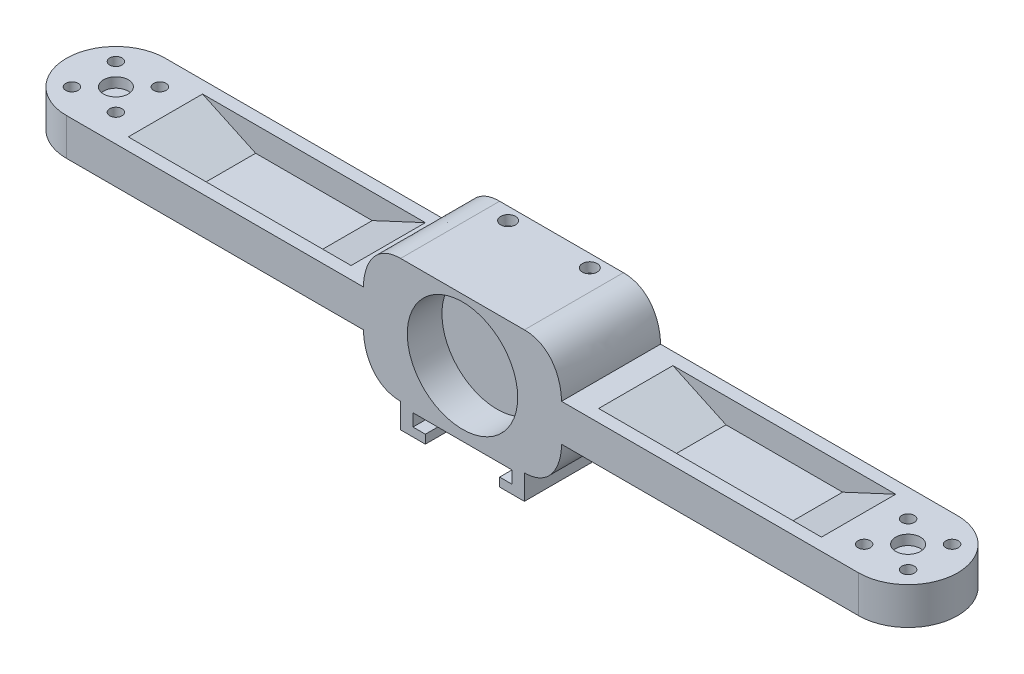
from build123d import *

# Parameters (mm, degrees)
BOSS_EXTRUDE1_DEPTH = 25
SKETCH2_R           = 11.15
CUT_EXTRUDE1_DEPTH  = 7
CUT_EXTRUDE2_DEPTH  = 8.75
CUT_EXTRUDE3_DEPTH  = 8.75
SKETCH5_W           = 25
SKETCH5_H           = 20.5
CUT_EXTRUDE4_DEPTH  = 8
SKETCH9_R           = 2.5
CUT_EXTRUDE5_DEPTH  = 2
CUT_EXTRUDE6_REACH  = 18.25
SKETCH10_R          = 1.25
SKETCH13_R          = 2.4
CUT_EXTRUDE7_DEPTH  = 4.5
SKETCH14_R          = 1.5
CUT_EXTRUDE8_DEPTH  = 2
CUT_EXTRUDE10_DEPTH = 20
BOSS_EXTRUDE2_DEPTH = 20
SKETCH18_W          = 45
SKETCH18_H          = 15
CUT_EXTRUDE11_DEPTH = 5
BOSS_EXTRUDE3_DEPTH = 20


with BuildPart() as part:
    # Sketch1 → Boss-Extrude1 (new body)
    with BuildSketch(Plane(origin=(0, 0, 0), x_dir=(1, 0, 0), z_dir=(0, 1, 0))):
        with BuildLine():
            Line((-80, 10), (80, 10))
            ThreePointArc((80, 10), (90, 0), (80, -10))
            Line((80, -10), (-80, -10))
            ThreePointArc((-80, -10), (-90, 0), (-80, 10))
        make_face()
    extrude(amount=BOSS_EXTRUDE1_DEPTH)

    # Sketch2 → Cut-Extrude1 (cut)
    with BuildSketch(Plane.XY.offset(10)):
        with Locations((0, 12.5)):
            Circle(SKETCH2_R)
    extrude(amount=-CUT_EXTRUDE1_DEPTH, mode=Mode.SUBTRACT)

    # Sketch3 → Cut-Extrude2 (cut)
    with BuildSketch(Plane(origin=(0, 25, 0), x_dir=(1, 0, 0), z_dir=(0, 1, 0))):
        with BuildLine():
            Line((-20, 10), (-20, -10))
            Line((-20, -10), (-80, -10))
            ThreePointArc((-80, -10), (-90, 0), (-80, 10))
            Line((-80, 10), (-20, 10))
        make_face()
        with BuildLine():
            Line((20, 10), (20, -10))
            Line((20, -10), (80, -10))
            ThreePointArc((80, -10), (90, 0), (80, 10))
            Line((80, 10), (20, 10))
        make_face()
    extrude(amount=-CUT_EXTRUDE2_DEPTH, mode=Mode.SUBTRACT)

    # Sketch4 → Cut-Extrude3 (cut)
    with BuildSketch(Plane.XZ):
        with BuildLine():
            Line((20, 10), (20, -10))
            Line((20, -10), (80, -10))
            ThreePointArc((80, -10), (90, 0), (80, 10))
            Line((80, 10), (20, 10))
        make_face()
        with BuildLine():
            Line((-20, 10), (-20, -10))
            Line((-20, -10), (-80, -10))
            ThreePointArc((-80, -10), (-90, 0), (-80, 10))
            Line((-80, 10), (-20, 10))
        make_face()
    extrude(amount=-CUT_EXTRUDE3_DEPTH, mode=Mode.SUBTRACT)

    # Sketch5 → Cut-Extrude4 (cut)
    with BuildSketch(Plane(origin=(0, 0, -10), x_dir=(-1, 0, 0), z_dir=(0, 0, -1))):
        with Locations((0, 12.5)):
            Rectangle(SKETCH5_W, SKETCH5_H)
    extrude(amount=-CUT_EXTRUDE4_DEPTH, mode=Mode.SUBTRACT)

    # Sketch9 → Cut-Extrude5 (cut)
    with BuildSketch(Plane(origin=(0, 16.25, 0), x_dir=(1, 0, 0), z_dir=(0, 1, 0))):
        with Locations((-80, 0)):
            Circle(SKETCH9_R)
        with Locations((80, 0)):
            Circle(SKETCH9_R)
    extrude(amount=-CUT_EXTRUDE5_DEPTH, mode=Mode.SUBTRACT)

    # Sketch10 → Cut-Extrude6 (cut, up to next)
    with BuildSketch(Plane(origin=(0, 16.25, 0), x_dir=(1, 0, 0), z_dir=(0, 1, 0)), mode=Mode.PRIVATE) as cut_extrude6_sk1:
        with Locations((-75.56, 4.44)):
            Circle(SKETCH10_R)
    cut_extrude6_tool1 = extrude(cut_extrude6_sk1.sketch, amount=-CUT_EXTRUDE6_REACH, mode=Mode.PRIVATE) & part.part
    add(cut_extrude6_tool1.solids().sort_by_distance((-75.56, 16.25, -4.44))[0], mode=Mode.SUBTRACT)
    # Sketch10 → Cut-Extrude6 (cut, up to next)
    with BuildSketch(Plane(origin=(0, 16.25, 0), x_dir=(1, 0, 0), z_dir=(0, 1, 0)), mode=Mode.PRIVATE) as cut_extrude6_sk2:
        with Locations((-75.56, -4.44)):
            Circle(SKETCH10_R)
    cut_extrude6_tool2 = extrude(cut_extrude6_sk2.sketch, amount=-CUT_EXTRUDE6_REACH, mode=Mode.PRIVATE) & part.part
    add(cut_extrude6_tool2.solids().sort_by_distance((-75.56, 16.25, 4.44))[0], mode=Mode.SUBTRACT)
    # Sketch10 → Cut-Extrude6 (cut, up to next)
    with BuildSketch(Plane(origin=(0, 16.25, 0), x_dir=(1, 0, 0), z_dir=(0, 1, 0)), mode=Mode.PRIVATE) as cut_extrude6_sk3:
        with Locations((-84.44, -4.44)):
            Circle(SKETCH10_R)
    cut_extrude6_tool3 = extrude(cut_extrude6_sk3.sketch, amount=-CUT_EXTRUDE6_REACH, mode=Mode.PRIVATE) & part.part
    add(cut_extrude6_tool3.solids().sort_by_distance((-84.44, 16.25, 4.44))[0], mode=Mode.SUBTRACT)
    # Sketch10 → Cut-Extrude6 (cut, up to next)
    with BuildSketch(Plane(origin=(0, 16.25, 0), x_dir=(1, 0, 0), z_dir=(0, 1, 0)), mode=Mode.PRIVATE) as cut_extrude6_sk4:
        with Locations((-84.44, 4.44)):
            Circle(SKETCH10_R)
    cut_extrude6_tool4 = extrude(cut_extrude6_sk4.sketch, amount=-CUT_EXTRUDE6_REACH, mode=Mode.PRIVATE) & part.part
    add(cut_extrude6_tool4.solids().sort_by_distance((-84.44, 16.25, -4.44))[0], mode=Mode.SUBTRACT)
    # Sketch10 → Cut-Extrude6 (cut, up to next)
    with BuildSketch(Plane(origin=(0, 16.25, 0), x_dir=(1, 0, 0), z_dir=(0, 1, 0)), mode=Mode.PRIVATE) as cut_extrude6_sk5:
        with Locations((84.44, 4.44)):
            Circle(SKETCH10_R)
    cut_extrude6_tool5 = extrude(cut_extrude6_sk5.sketch, amount=-CUT_EXTRUDE6_REACH, mode=Mode.PRIVATE) & part.part
    add(cut_extrude6_tool5.solids().sort_by_distance((84.44, 16.25, -4.44))[0], mode=Mode.SUBTRACT)
    # Sketch10 → Cut-Extrude6 (cut, up to next)
    with BuildSketch(Plane(origin=(0, 16.25, 0), x_dir=(1, 0, 0), z_dir=(0, 1, 0)), mode=Mode.PRIVATE) as cut_extrude6_sk6:
        with Locations((84.44, -4.44)):
            Circle(SKETCH10_R)
    cut_extrude6_tool6 = extrude(cut_extrude6_sk6.sketch, amount=-CUT_EXTRUDE6_REACH, mode=Mode.PRIVATE) & part.part
    add(cut_extrude6_tool6.solids().sort_by_distance((84.44, 16.25, 4.44))[0], mode=Mode.SUBTRACT)
    # Sketch10 → Cut-Extrude6 (cut, up to next)
    with BuildSketch(Plane(origin=(0, 16.25, 0), x_dir=(1, 0, 0), z_dir=(0, 1, 0)), mode=Mode.PRIVATE) as cut_extrude6_sk7:
        with Locations((75.56, -4.44)):
            Circle(SKETCH10_R)
    cut_extrude6_tool7 = extrude(cut_extrude6_sk7.sketch, amount=-CUT_EXTRUDE6_REACH, mode=Mode.PRIVATE) & part.part
    add(cut_extrude6_tool7.solids().sort_by_distance((75.56, 16.25, 4.44))[0], mode=Mode.SUBTRACT)
    # Sketch10 → Cut-Extrude6 (cut, up to next)
    with BuildSketch(Plane(origin=(0, 16.25, 0), x_dir=(1, 0, 0), z_dir=(0, 1, 0)), mode=Mode.PRIVATE) as cut_extrude6_sk8:
        with Locations((75.56, 4.44)):
            Circle(SKETCH10_R)
    cut_extrude6_tool8 = extrude(cut_extrude6_sk8.sketch, amount=-CUT_EXTRUDE6_REACH, mode=Mode.PRIVATE) & part.part
    add(cut_extrude6_tool8.solids().sort_by_distance((75.56, 16.25, -4.44))[0], mode=Mode.SUBTRACT)

    # Sketch13 → Cut-Extrude7 (cut)
    with BuildSketch(Plane.XZ.offset(-8.75)):
        with Locations((-75.56, 4.44)):
            Circle(SKETCH13_R)
        with Locations((-75.56, -4.44)):
            Circle(SKETCH13_R)
        with Locations((-84.44, -4.44)):
            Circle(SKETCH13_R)
        with Locations((-84.44, 4.44)):
            Circle(SKETCH13_R)
        with Locations((84.44, 4.44)):
            Circle(SKETCH13_R)
        with Locations((84.44, -4.44)):
            Circle(SKETCH13_R)
        with Locations((75.56, -4.44)):
            Circle(SKETCH13_R)
        with Locations((75.56, 4.44)):
            Circle(SKETCH13_R)
    extrude(amount=-CUT_EXTRUDE7_DEPTH, mode=Mode.SUBTRACT)

    # Sketch14 → Cut-Extrude8 (cut)
    with BuildSketch(Plane(origin=(0, 25, 0), x_dir=(1, 0, 0), z_dir=(0, 1, 0))):
        with Locations((-8.25, 7.46)):
            Circle(SKETCH14_R)
        with Locations((8.25, 7.46)):
            Circle(SKETCH14_R)
    extrude(amount=-CUT_EXTRUDE8_DEPTH, mode=Mode.SUBTRACT)

    # Sketch16 → Cut-Extrude10 (cut)
    with BuildSketch(Plane(origin=(0, 0, -10), x_dir=(-1, 0, 0), z_dir=(0, 0, -1))):
        with BuildLine():
            Line((-12.5, 25), (-20, 25))
            Line((-20, 25), (-20, 16.25))
            add(Edge.make_bspline(
                [(-20, 16.25), (-20, 20.091476857), (-17.882145689, 25), (-12.5, 25)],
                knots=[0, 0, 0, 0, 1, 1, 1, 1], degree=3))
        make_face()
        with BuildLine():
            Line((12.5, 25), (20, 25))
            Line((20, 25), (20, 16.25))
            add(Edge.make_bspline(
                [(20, 16.25), (20, 20.091476857), (17.882145689, 25), (12.5, 25)],
                knots=[0, 0, 0, 0, 1, 1, 1, 1], degree=3))
        make_face()
        with BuildLine():
            Line((20, 0), (20, 8.75))
            add(Edge.make_bspline(
                [(20, 8.75), (20, 4.908523143), (17.882145689, 0), (12.5, 0)],
                knots=[0, 0, 0, 0, 1, 1, 1, 1], degree=3))
            Line((12.5, 0), (20, 0))
        make_face()
        with BuildLine():
            Line((-20, 0), (-20, 8.75))
            add(Edge.make_bspline(
                [(-20, 8.75), (-20, 4.908523143), (-17.882145689, 0), (-12.5, 0)],
                knots=[0, 0, 0, 0, 1, 1, 1, 1], degree=3))
            Line((-12.5, 0), (-20, 0))
        make_face()
    extrude(amount=-CUT_EXTRUDE10_DEPTH, mode=Mode.SUBTRACT)

    # Sketch17 → Boss-Extrude2 (add)
    with BuildSketch(Plane(origin=(0, 0, -10), x_dir=(-1, 0, 0), z_dir=(0, 0, -1))):
        Polygon((12.5, 0), (12.5, -5), (7.5, -5), (7.5, -3.25), (10, -3.25), (10, -0.75), (-10, -0.75), (-10, -3.25), (-7.5, -3.25), (-7.5, -5), (-12.5, -5), (-12.5, 0), align=None)
    extrude(amount=-BOSS_EXTRUDE2_DEPTH)

    # Sketch18 → Cut-Extrude11 (cut)
    with BuildSketch(Plane(origin=(0, 16.25, 0), x_dir=(1, 0, 0), z_dir=(0, 1, 0))):
        with Locations((47.5, 0)):
            Rectangle(SKETCH18_W, SKETCH18_H)
        with Locations((-47.5, 0)):
            Rectangle(SKETCH18_W, SKETCH18_H)
    extrude(amount=-CUT_EXTRUDE11_DEPTH, mode=Mode.SUBTRACT)

    # Sketch20 → Boss-Extrude3 (add)
    with BuildSketch(Plane.XY.offset(10)):
        Polygon((-25, 11.25), (-25, 16.25), (-35.722534603, 11.25), align=None)
        Polygon((-70, 11.25), (-59.277465397, 11.25), (-70, 16.25), align=None)
        Polygon((25, 11.25), (35.722534603, 11.25), (25, 16.25), align=None)
        Polygon((70, 11.25), (70, 16.25), (59.277465397, 11.25), align=None)
    extrude(amount=-BOSS_EXTRUDE3_DEPTH)


solid = part.part
